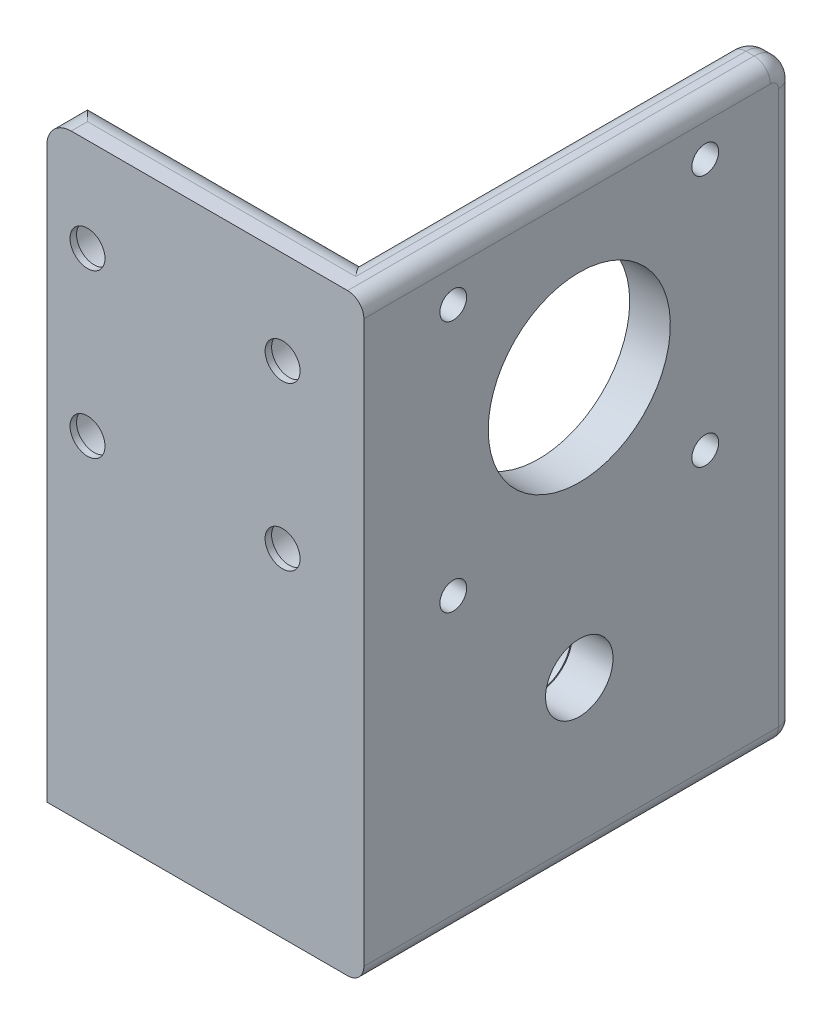
from build123d import *

# Parameters (mm, degrees)
SKETCH1_W           = 34
SKETCH1_H           = 43
SKETCH1_R           = 2.15
BOSS_EXTRUDE2_DEPTH = 5
SKETCH2_W           = 5
SKETCH2_H           = 43
BOSS_EXTRUDE3_DEPTH = 53
SKETCH3_R           = 3.55
SKETCH3_R_2         = 2.15
CUT_EXTRUDE1_DEPTH  = 4.2
SKETCH5_R           = 1.65
SKETCH5_R_2         = 11.2
CUT_EXTRUDE2_DEPTH  = 5
FILLET1_R           = 3
BOSS_EXTRUDE6_DEPTH = 30
SKETCH9_R           = 4.15
CUT_EXTRUDE3_DEPTH  = 10
BOSS_EXTRUDE9_DEPTH = 17
SKETCH11_R          = 4
CUT_EXTRUDE4_DEPTH  = 5
FILLET5_R           = 2
FILLET6_R           = 2
FILLET7_R           = 2


with BuildPart() as part:
    # Sketch1 → Boss-Extrude2 (new body)
    with BuildSketch(Plane.XY):
        with Locations((17, 21.5)):
            Rectangle(SKETCH1_W, SKETCH1_H)
        with Locations((5, 31.5)):
            Circle(SKETCH1_R, mode=Mode.SUBTRACT)
        with Locations((29, 31.5)):
            Circle(SKETCH1_R, mode=Mode.SUBTRACT)
        with Locations((5, 11.5)):
            Circle(SKETCH1_R, mode=Mode.SUBTRACT)
        with Locations((29, 11.5)):
            Circle(SKETCH1_R, mode=Mode.SUBTRACT)
    extrude(amount=BOSS_EXTRUDE2_DEPTH)

    # Sketch2 → Boss-Extrude3 (add)
    with BuildSketch(Plane.XY.offset(5)):
        with Locations((36.5, 21.5)):
            Rectangle(SKETCH2_W, SKETCH2_H)
    extrude(amount=-BOSS_EXTRUDE3_DEPTH)

    # Sketch3 → Cut-Extrude1 (cut)
    with BuildSketch(Plane(origin=(0, 0, 0), x_dir=(-1, 0, 0), z_dir=(0, 0, -1))):
        with Locations((-29, 31.5)):
            Circle(SKETCH3_R)
        with Locations((-29, 31.5)):
            Circle(SKETCH3_R_2, mode=Mode.SUBTRACT)
        with Locations((-5, 31.5)):
            Circle(SKETCH3_R)
        with Locations((-5, 31.5)):
            Circle(SKETCH3_R_2, mode=Mode.SUBTRACT)
        with Locations((-5, 11.5)):
            Circle(SKETCH3_R)
        with Locations((-5, 11.5)):
            Circle(SKETCH3_R_2, mode=Mode.SUBTRACT)
        with Locations((-29, 11.5)):
            Circle(SKETCH3_R)
        with Locations((-29, 11.5)):
            Circle(SKETCH3_R_2, mode=Mode.SUBTRACT)
    extrude(amount=-CUT_EXTRUDE1_DEPTH, mode=Mode.SUBTRACT)

    # Sketch5 → Cut-Extrude2 (cut)
    with BuildSketch(Plane.ZY.offset(-34)):
        with Locations((-6, 6)):
            Circle(SKETCH5_R)
        with Locations((-37, 6)):
            Circle(SKETCH5_R)
        with Locations((-37, 37)):
            Circle(SKETCH5_R)
        with Locations((-21.5, 21.5)):
            Circle(SKETCH5_R_2)
        with Locations((-6, 37)):
            Circle(SKETCH5_R)
    extrude(amount=-CUT_EXTRUDE2_DEPTH, mode=Mode.SUBTRACT)

    # Fillet1
    fillet1_edges = [part.edges().sort_by_distance(p)[0] for p in [
        (36.5, 43, -48),
        (17, 43, 0),
        (0, 43, 2.5),
    ]]
    fillet(fillet1_edges, radius=FILLET1_R)

    # Sketch7 → Boss-Extrude6 (add)
    with BuildSketch(Plane.XZ):
        Polygon((0, 5), (39, 5), (39, 0), (39, -48), (34, -48), (34, 0), (0, 0), align=None)
    extrude(amount=BOSS_EXTRUDE6_DEPTH)

    # Sketch9 → Cut-Extrude3 (cut)
    with BuildSketch(Plane(origin=(39, 0, 0), x_dir=(0, 0, -1), z_dir=(1, 0, 0))):
        with Locations((21.5, -10.5)):
            Circle(SKETCH9_R)
    extrude(amount=-CUT_EXTRUDE3_DEPTH, mode=Mode.SUBTRACT)

    # Sketch10 → Boss-Extrude9 (add)
    with BuildSketch(Plane.ZY.offset(-34)):
        with BuildLine():
            Line((0, -3.5), (-21.5, -3.5))
            ThreePointArc((-21.5, -3.5), (-28.5, -10.5), (-21.5, -17.5))
            Line((-21.5, -17.5), (0, -17.5))
            Line((0, -17.5), (0, -3.5))
        make_face()
    extrude(amount=BOSS_EXTRUDE9_DEPTH)

    # Sketch11 → Cut-Extrude4 (cut)
    with BuildSketch(Plane(origin=(34, 0, 0), x_dir=(0, 0, -1), z_dir=(1, 0, 0))):
        with Locations((21.5, -10.5)):
            Circle(SKETCH11_R)
    extrude(amount=-CUT_EXTRUDE4_DEPTH, mode=Mode.SUBTRACT)

    # Fillet5
    fillet5_edges = [part.edges().sort_by_distance(p)[0] for p in [
        (17, -30, 0),
        (36.5, -30, -48),
    ]]
    fillet(fillet5_edges, radius=FILLET5_R)

    # Fillet6
    fillet6_edges = [part.edges().sort_by_distance(p)[0] for p in [
        (25.5, -3.5, 0),
        (25.5, -17.5, 0),
        (17, -10.5, 0),
    ]]
    fillet(fillet6_edges, radius=FILLET6_R)

    # Fillet7
    fillet7_edges = [part.edges().sort_by_distance(p)[0] for p in [
        (39, -30, -20.5),
        (39, -29.414213562, -47.414213562),
        (39, 43, -20),
        (39, 42.121320344, -47.121320344),
        (34, 43, -21),
        (34, 42.121320344, -47.121320344),
        (34, -30, -23),
        (34, -29.414213562, -47.414213562),
        (39, 6, -48),
        (34, 6, -48),
    ]]
    fillet(fillet7_edges, radius=FILLET7_R)


solid = part.part
